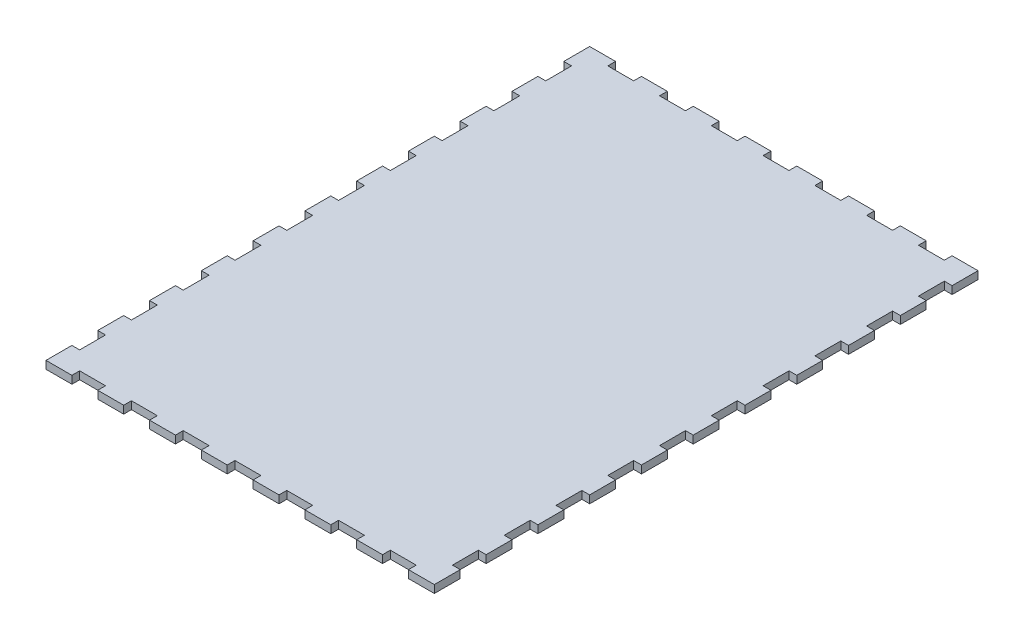
from build123d import *

# Parameters (mm, degrees)
SKETCH1_W               = 150
SKETCH1_H               = 210
BOSS_EXTRUDE1_DEPTH     = 3
SKETCH2_W               = 10
SKETCH2_H               = 3
CUT_EXTRUDE1_DEPTH      = 3
LPATTERN1_COUNT         = 7
LPATTERN1_PITCH         = 20
MIRROR1_COPY_1_SKETCH_W = 10
MIRROR1_COPY_1_SKETCH_H = 3
MIRROR1_COPY_1_DEPTH    = 3
MIRROR1_COPY_2_SKETCH_W = 10
MIRROR1_COPY_2_SKETCH_H = 3
MIRROR1_COPY_2_DEPTH    = 3
MIRROR1_COPY_3_SKETCH_W = 10
MIRROR1_COPY_3_SKETCH_H = 3
MIRROR1_COPY_3_DEPTH    = 3
MIRROR1_COPY_4_SKETCH_W = 10
MIRROR1_COPY_4_SKETCH_H = 3
MIRROR1_COPY_4_DEPTH    = 3
MIRROR1_COPY_5_SKETCH_W = 10
MIRROR1_COPY_5_SKETCH_H = 3
MIRROR1_COPY_5_DEPTH    = 3
MIRROR1_COPY_6_SKETCH_W = 10
MIRROR1_COPY_6_SKETCH_H = 3
MIRROR1_COPY_6_DEPTH    = 3
SKETCH4_W               = 3
SKETCH4_H               = 10
CUT_EXTRUDE2_DEPTH      = 3
LPATTERN2_COUNT         = 10
LPATTERN2_PITCH         = 20
MIRROR2_COPY_1_SKETCH_W = 3
MIRROR2_COPY_1_SKETCH_H = 10
MIRROR2_COPY_1_DEPTH    = 3
MIRROR2_COPY_2_SKETCH_W = 3
MIRROR2_COPY_2_SKETCH_H = 10
MIRROR2_COPY_2_DEPTH    = 3
MIRROR2_COPY_3_SKETCH_W = 3
MIRROR2_COPY_3_SKETCH_H = 10
MIRROR2_COPY_3_DEPTH    = 3
MIRROR2_COPY_4_SKETCH_W = 3
MIRROR2_COPY_4_SKETCH_H = 10
MIRROR2_COPY_4_DEPTH    = 3
MIRROR2_COPY_5_SKETCH_W = 3
MIRROR2_COPY_5_SKETCH_H = 10
MIRROR2_COPY_5_DEPTH    = 3
MIRROR2_COPY_6_SKETCH_W = 3
MIRROR2_COPY_6_SKETCH_H = 10
MIRROR2_COPY_6_DEPTH    = 3
MIRROR2_COPY_7_SKETCH_W = 3
MIRROR2_COPY_7_SKETCH_H = 10
MIRROR2_COPY_7_DEPTH    = 3
MIRROR2_COPY_8_SKETCH_W = 3
MIRROR2_COPY_8_SKETCH_H = 10
MIRROR2_COPY_8_DEPTH    = 3
MIRROR2_COPY_9_SKETCH_W = 3
MIRROR2_COPY_9_SKETCH_H = 10
MIRROR2_COPY_9_DEPTH    = 3


with BuildPart() as part:
    # Sketch1 → Boss-Extrude1 (new body)
    with BuildSketch(Plane(origin=(0, 0, 0), x_dir=(1, 0, 0), z_dir=(0, 1, 0))):
        Rectangle(SKETCH1_W, SKETCH1_H)
    extrude(amount=BOSS_EXTRUDE1_DEPTH)

    # Sketch2 → Cut-Extrude1 (cut)
    with BuildSketch(Plane(origin=(0, 3, 0), x_dir=(1, 0, 0), z_dir=(0, 1, 0))):
        with Locations((-60, 103.5)):
            Rectangle(SKETCH2_W, SKETCH2_H)
    cut_extrude1 = extrude(amount=-CUT_EXTRUDE1_DEPTH, mode=Mode.SUBTRACT)

    # LPattern1: Cut-Extrude1 ×7
    with Locations(*[(i * LPATTERN1_PITCH, 0, 0) for i in range(1, LPATTERN1_COUNT)]):
        add(cut_extrude1, mode=Mode.SUBTRACT)

    # Mirror1: Cut-Extrude1 across plane
    add(cut_extrude1.mirror(Plane.XY), mode=Mode.SUBTRACT)

    # Mirror1 copy 1 sketch → Mirror1 copy 1 (cut)
    with BuildSketch(Plane(origin=(20, 3, 0), x_dir=(1, 0, 0), z_dir=(0, 1, 0))):
        with Locations((-60, -103.5)):
            Rectangle(MIRROR1_COPY_1_SKETCH_W, MIRROR1_COPY_1_SKETCH_H)
    extrude(amount=-MIRROR1_COPY_1_DEPTH, mode=Mode.SUBTRACT)

    # Mirror1 copy 2 sketch → Mirror1 copy 2 (cut)
    with BuildSketch(Plane(origin=(40, 3, 0), x_dir=(1, 0, 0), z_dir=(0, 1, 0))):
        with Locations((-60, -103.5)):
            Rectangle(MIRROR1_COPY_2_SKETCH_W, MIRROR1_COPY_2_SKETCH_H)
    extrude(amount=-MIRROR1_COPY_2_DEPTH, mode=Mode.SUBTRACT)

    # Mirror1 copy 3 sketch → Mirror1 copy 3 (cut)
    with BuildSketch(Plane(origin=(60, 3, 0), x_dir=(1, 0, 0), z_dir=(0, 1, 0))):
        with Locations((-60, -103.5)):
            Rectangle(MIRROR1_COPY_3_SKETCH_W, MIRROR1_COPY_3_SKETCH_H)
    extrude(amount=-MIRROR1_COPY_3_DEPTH, mode=Mode.SUBTRACT)

    # Mirror1 copy 4 sketch → Mirror1 copy 4 (cut)
    with BuildSketch(Plane(origin=(80, 3, 0), x_dir=(1, 0, 0), z_dir=(0, 1, 0))):
        with Locations((-60, -103.5)):
            Rectangle(MIRROR1_COPY_4_SKETCH_W, MIRROR1_COPY_4_SKETCH_H)
    extrude(amount=-MIRROR1_COPY_4_DEPTH, mode=Mode.SUBTRACT)

    # Mirror1 copy 5 sketch → Mirror1 copy 5 (cut)
    with BuildSketch(Plane(origin=(100, 3, 0), x_dir=(1, 0, 0), z_dir=(0, 1, 0))):
        with Locations((-60, -103.5)):
            Rectangle(MIRROR1_COPY_5_SKETCH_W, MIRROR1_COPY_5_SKETCH_H)
    extrude(amount=-MIRROR1_COPY_5_DEPTH, mode=Mode.SUBTRACT)

    # Mirror1 copy 6 sketch → Mirror1 copy 6 (cut)
    with BuildSketch(Plane(origin=(120, 3, 0), x_dir=(1, 0, 0), z_dir=(0, 1, 0))):
        with Locations((-60, -103.5)):
            Rectangle(MIRROR1_COPY_6_SKETCH_W, MIRROR1_COPY_6_SKETCH_H)
    extrude(amount=-MIRROR1_COPY_6_DEPTH, mode=Mode.SUBTRACT)

    # Sketch4 → Cut-Extrude2 (cut)
    with BuildSketch(Plane(origin=(0, 3, 0), x_dir=(1, 0, 0), z_dir=(0, 1, 0))):
        with Locations((-73.5, 90)):
            Rectangle(SKETCH4_W, SKETCH4_H)
    cut_extrude2 = extrude(amount=-CUT_EXTRUDE2_DEPTH, mode=Mode.SUBTRACT)

    # LPattern2: Cut-Extrude2 ×10
    with Locations(*[(0, 0, i * LPATTERN2_PITCH) for i in range(1, LPATTERN2_COUNT)]):
        add(cut_extrude2, mode=Mode.SUBTRACT)

    # Mirror2: Cut-Extrude2 across plane
    add(cut_extrude2.mirror(Plane(origin=(0, 0, 0), x_dir=(0, 0, 1), z_dir=(1, 0, 0))), mode=Mode.SUBTRACT)

    # Mirror2 copy 1 sketch → Mirror2 copy 1 (cut)
    with BuildSketch(Plane(origin=(0, 3, 20), x_dir=(-1, 0, 0), z_dir=(0, 1, 0))):
        with Locations((-73.5, -90)):
            Rectangle(MIRROR2_COPY_1_SKETCH_W, MIRROR2_COPY_1_SKETCH_H)
    extrude(amount=-MIRROR2_COPY_1_DEPTH, mode=Mode.SUBTRACT)

    # Mirror2 copy 2 sketch → Mirror2 copy 2 (cut)
    with BuildSketch(Plane(origin=(0, 3, 40), x_dir=(-1, 0, 0), z_dir=(0, 1, 0))):
        with Locations((-73.5, -90)):
            Rectangle(MIRROR2_COPY_2_SKETCH_W, MIRROR2_COPY_2_SKETCH_H)
    extrude(amount=-MIRROR2_COPY_2_DEPTH, mode=Mode.SUBTRACT)

    # Mirror2 copy 3 sketch → Mirror2 copy 3 (cut)
    with BuildSketch(Plane(origin=(0, 3, 60), x_dir=(-1, 0, 0), z_dir=(0, 1, 0))):
        with Locations((-73.5, -90)):
            Rectangle(MIRROR2_COPY_3_SKETCH_W, MIRROR2_COPY_3_SKETCH_H)
    extrude(amount=-MIRROR2_COPY_3_DEPTH, mode=Mode.SUBTRACT)

    # Mirror2 copy 4 sketch → Mirror2 copy 4 (cut)
    with BuildSketch(Plane(origin=(0, 3, 80), x_dir=(-1, 0, 0), z_dir=(0, 1, 0))):
        with Locations((-73.5, -90)):
            Rectangle(MIRROR2_COPY_4_SKETCH_W, MIRROR2_COPY_4_SKETCH_H)
    extrude(amount=-MIRROR2_COPY_4_DEPTH, mode=Mode.SUBTRACT)

    # Mirror2 copy 5 sketch → Mirror2 copy 5 (cut)
    with BuildSketch(Plane(origin=(0, 3, 100), x_dir=(-1, 0, 0), z_dir=(0, 1, 0))):
        with Locations((-73.5, -90)):
            Rectangle(MIRROR2_COPY_5_SKETCH_W, MIRROR2_COPY_5_SKETCH_H)
    extrude(amount=-MIRROR2_COPY_5_DEPTH, mode=Mode.SUBTRACT)

    # Mirror2 copy 6 sketch → Mirror2 copy 6 (cut)
    with BuildSketch(Plane(origin=(0, 3, 120), x_dir=(-1, 0, 0), z_dir=(0, 1, 0))):
        with Locations((-73.5, -90)):
            Rectangle(MIRROR2_COPY_6_SKETCH_W, MIRROR2_COPY_6_SKETCH_H)
    extrude(amount=-MIRROR2_COPY_6_DEPTH, mode=Mode.SUBTRACT)

    # Mirror2 copy 7 sketch → Mirror2 copy 7 (cut)
    with BuildSketch(Plane(origin=(0, 3, 140), x_dir=(-1, 0, 0), z_dir=(0, 1, 0))):
        with Locations((-73.5, -90)):
            Rectangle(MIRROR2_COPY_7_SKETCH_W, MIRROR2_COPY_7_SKETCH_H)
    extrude(amount=-MIRROR2_COPY_7_DEPTH, mode=Mode.SUBTRACT)

    # Mirror2 copy 8 sketch → Mirror2 copy 8 (cut)
    with BuildSketch(Plane(origin=(0, 3, 160), x_dir=(-1, 0, 0), z_dir=(0, 1, 0))):
        with Locations((-73.5, -90)):
            Rectangle(MIRROR2_COPY_8_SKETCH_W, MIRROR2_COPY_8_SKETCH_H)
    extrude(amount=-MIRROR2_COPY_8_DEPTH, mode=Mode.SUBTRACT)

    # Mirror2 copy 9 sketch → Mirror2 copy 9 (cut)
    with BuildSketch(Plane(origin=(0, 3, 180), x_dir=(-1, 0, 0), z_dir=(0, 1, 0))):
        with Locations((-73.5, -90)):
            Rectangle(MIRROR2_COPY_9_SKETCH_W, MIRROR2_COPY_9_SKETCH_H)
    extrude(amount=-MIRROR2_COPY_9_DEPTH, mode=Mode.SUBTRACT)


solid = part.part
